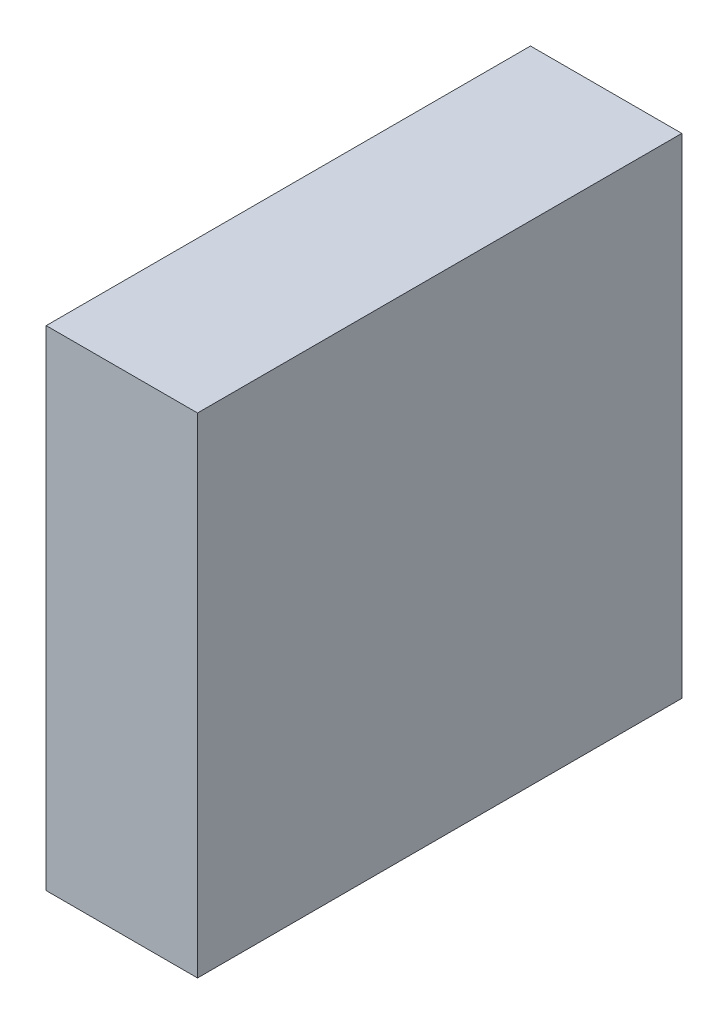
from build123d import *

# Parameters (mm, degrees)
ESQUISSE1_W        = 96
ESQUISSE1_H        = 97
BOSS_EXTRU_1_DEPTH = 30


with BuildPart() as part:
    # Esquisse1 → Boss.-Extru.1 (new body)
    with BuildSketch(Plane(origin=(0, 0, 0), x_dir=(0, 0, -1), z_dir=(1, 0, 0))):
        Rectangle(ESQUISSE1_W, ESQUISSE1_H)
    extrude(amount=BOSS_EXTRU_1_DEPTH)


solid = part.part
